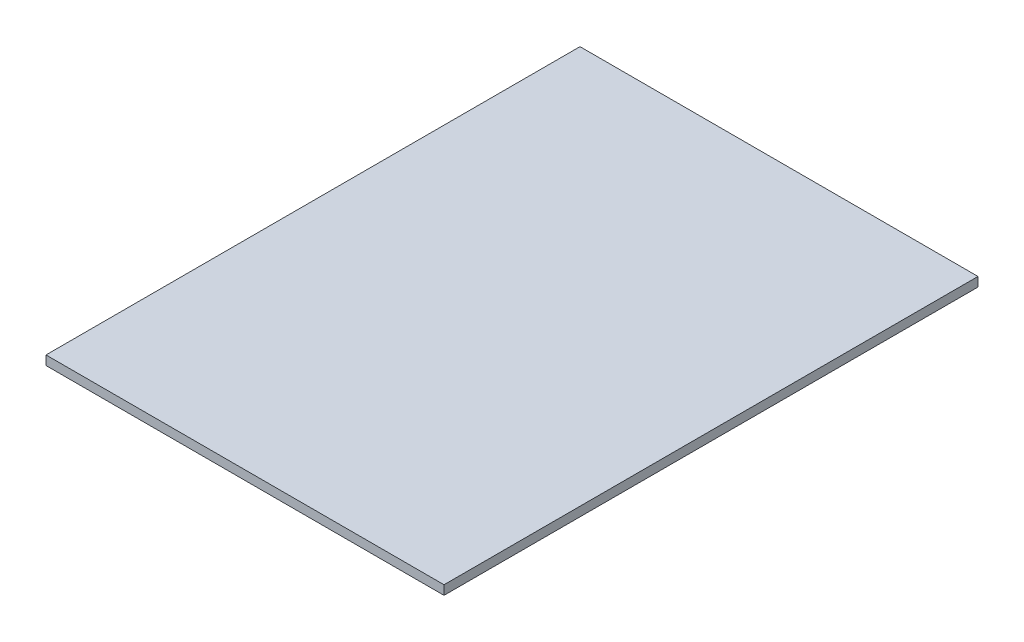
from build123d import *

# Parameters (mm, degrees)
SKETCH1_W           = 87.828
SKETCH1_H           = 117.828
BOSS_EXTRUDE1_DEPTH = 2.032


with BuildPart() as part:
    # Sketch1 → Boss-Extrude1 (new body)
    with BuildSketch(Plane(origin=(0, 0, 0), x_dir=(1, 0, 0), z_dir=(0, 1, 0))):
        with Locations((43.914, 58.914)):
            Rectangle(SKETCH1_W, SKETCH1_H)
    extrude(amount=BOSS_EXTRUDE1_DEPTH)


solid = part.part
